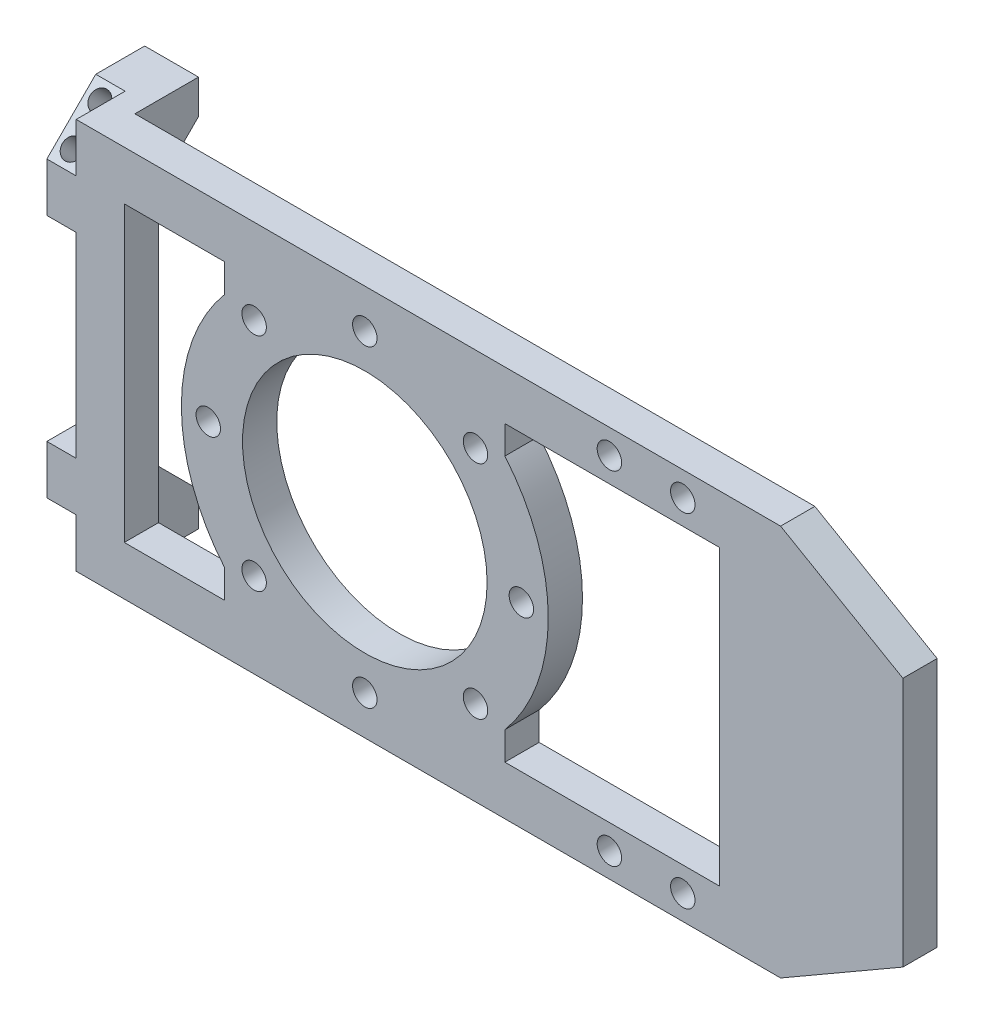
from build123d import *

# Parameters (mm, degrees)
SKETCH1_W           = 150
SKETCH1_H           = 80
BOSS_EXTRUDE1_DEPTH = 7
SKETCH2_W           = 6
SKETCH2_H           = 40
CUT_EXTRUDE2_DEPTH  = 7
SKETCH3_R           = 25
CUT_EXTRUDE3_DEPTH  = 7
CUT_EXTRUDE5_DEPTH  = 7
CUT_EXTRUDE6_DEPTH  = 7
SKETCH6_R           = 2.5
CUT_EXTRUDE7_DEPTH  = 7
BOSS_EXTRUDE2_DEPTH = 6
CUT_EXTRUDE8_DEPTH  = 6
SKETCH10_W          = 6
SKETCH10_H          = 20
BOSS_EXTRUDE3_DEPTH = 13
CUT_EXTRUDE9_DEPTH  = 13
SKETCH12_R          = 2.5
CUT_EXTRUDE10_DEPTH = 13
BOSS_EXTRUDE5_DEPTH = 5
SKETCH14_R          = 2
CUT_EXTRUDE11_DEPTH = 20.091883092
CUT_EXTRUDE13_DEPTH = 6
BOSS_EXTRUDE6_DEPTH = 7


with BuildPart() as part:
    # Sketch1 → Boss-Extrude1 (new body)
    with BuildSketch(Plane.XY):
        with Locations((75, 40)):
            Rectangle(SKETCH1_W, SKETCH1_H)
    extrude(amount=BOSS_EXTRUDE1_DEPTH)

    # Sketch2 → Cut-Extrude2 (cut)
    with BuildSketch(Plane.XY.offset(7)):
        with Locations((3, 40)):
            Rectangle(SKETCH2_W, SKETCH2_H)
    extrude(amount=-CUT_EXTRUDE2_DEPTH, mode=Mode.SUBTRACT)

    # Sketch3 → Cut-Extrude3 (cut)
    with BuildSketch(Plane.XY.offset(7)):
        with Locations((65, 40)):
            Circle(SKETCH3_R)
    extrude(amount=-CUT_EXTRUDE3_DEPTH, mode=Mode.SUBTRACT)

    # Sketch4 → Cut-Extrude5 (cut)
    with BuildSketch(Plane.XY.offset(7)):
        with BuildLine():
            Line((15.828446624, 69.975175599), (15.828446624, 10.024824401))
            Line((15.828446624, 10.024824401), (36.358795003, 10.024824401))
            Line((36.358795003, 10.024824401), (36.358795003, 15.793980576))
            ThreePointArc((36.358795003, 15.793980576), (27.5, 40), (36.358795003, 64.206019424))
            Line((36.358795003, 64.206019424), (36.358795003, 69.975175599))
            Line((36.358795003, 69.975175599), (15.828446624, 69.975175599))
        make_face()
    extrude(amount=-CUT_EXTRUDE5_DEPTH, mode=Mode.SUBTRACT)

    # Sketch5 → Cut-Extrude6 (cut)
    with BuildSketch(Plane.XY.offset(7)):
        with BuildLine():
            Line((93.631196157, 69.975175599), (93.631196157, 64.217857185))
            ThreePointArc((93.631196157, 64.217857185), (102.5, 40), (93.631196157, 15.782142815))
            Line((93.631196157, 15.782142815), (93.631196157, 10.024824401))
            Line((93.631196157, 10.024824401), (137.533061217, 10.024824401))
            Line((137.533061217, 10.024824401), (137.533061217, 69.975175599))
            Line((137.533061217, 69.975175599), (93.631196157, 69.975175599))
        make_face()
    extrude(amount=-CUT_EXTRUDE6_DEPTH, mode=Mode.SUBTRACT)

    # Sketch6 → Cut-Extrude7 (cut)
    with BuildSketch(Plane.XY.offset(7)):
        with Locations((97, 40)):
            Circle(SKETCH6_R)
        with Locations((87.627416998, 17.372583002)):
            Circle(SKETCH6_R)
        with Locations((65, 8)):
            Circle(SKETCH6_R)
        with Locations((42.372583002, 17.372583002)):
            Circle(SKETCH6_R)
        with Locations((33, 40)):
            Circle(SKETCH6_R)
        with Locations((42.372583002, 62.627416998)):
            Circle(SKETCH6_R)
        with Locations((65, 72)):
            Circle(SKETCH6_R)
        with Locations((87.627416998, 62.627416998)):
            Circle(SKETCH6_R)
    extrude(amount=-CUT_EXTRUDE7_DEPTH, mode=Mode.SUBTRACT)

    # Sketch8 → Boss-Extrude2 (add)
    with BuildSketch(Plane.ZY):
        Polygon((0, 60), (-20, 80), (0, 80), align=None)
    extrude(amount=-BOSS_EXTRUDE2_DEPTH)

    # Sketch9 → Cut-Extrude8 (cut)
    with BuildSketch(Plane.ZY):
        Polygon((-13, 80), (-13, 73), (-20, 80), align=None)
    extrude(amount=-CUT_EXTRUDE8_DEPTH, mode=Mode.SUBTRACT)

    # Sketch10 → Boss-Extrude3 (add)
    with BuildSketch(Plane(origin=(0, 0, 0), x_dir=(-1, 0, 0), z_dir=(0, 0, -1))):
        with Locations((-3, 10)):
            Rectangle(SKETCH10_W, SKETCH10_H)
    extrude(amount=BOSS_EXTRUDE3_DEPTH)

    # Sketch11 → Cut-Extrude9 (cut)
    with BuildSketch(Plane.ZY):
        Polygon((0, 20), (-13, 7), (-13, 20), align=None)
    extrude(amount=-CUT_EXTRUDE9_DEPTH, mode=Mode.SUBTRACT)

    # Sketch12 → Cut-Extrude10 (cut)
    with BuildSketch(Plane.XY.offset(7)):
        with Locations((130, 75)):
            Circle(SKETCH12_R)
        with Locations((115, 75)):
            Circle(SKETCH12_R)
        with Locations((130, 5)):
            Circle(SKETCH12_R)
        with Locations((115, 5)):
            Circle(SKETCH12_R)
    extrude(amount=-CUT_EXTRUDE10_DEPTH, mode=Mode.SUBTRACT)

    # Sketch13 → Boss-Extrude5 (add)
    with BuildSketch(Plane(origin=(6, 0, 0), x_dir=(0, 0, -1), z_dir=(1, 0, 0))):
        Polygon((0, 60), (13, 73), (13, 80), (0, 80), align=None)
        Polygon((13, 0), (0, 0), (0, 20), (13, 7), align=None)
    extrude(amount=BOSS_EXTRUDE5_DEPTH)

    # Sketch14 → Cut-Extrude11 (cut, through all)
    with BuildSketch(Plane(origin=(0, 30, 30), x_dir=(1, 0, 0), z_dir=(0, -0.707106781, -0.707106781))):
        with Locations((3, -47.618795027)):
            Circle(SKETCH14_R)
        with Locations((3, -55.618795027)):
            Circle(SKETCH14_R)
    cut_extrude11 = extrude(amount=-CUT_EXTRUDE11_DEPTH, mode=Mode.SUBTRACT)

    # Sketch15 → Cut-Extrude13 (cut)
    with BuildSketch(Plane.ZY):
        Polygon((7, 70), (-3, 80), (7, 80), align=None)
        Polygon((-3, 0), (7, 0), (7, 10), align=None)
    extrude(amount=-CUT_EXTRUDE13_DEPTH, mode=Mode.SUBTRACT)

    # Mirror1: Cut-Extrude11 across plane
    add(cut_extrude11.mirror(Plane(origin=(0, 40, 0), x_dir=(0, 0, 1), z_dir=(0, -1, 0))), mode=Mode.SUBTRACT)

    # Sketch17 → Boss-Extrude6 (add)
    with BuildSketch(Plane.XY.offset(7)):
        Polygon((150, 80), (175, 65.56624327), (175, 14.43375673), (150, 0), align=None)
    extrude(amount=-BOSS_EXTRUDE6_DEPTH)


solid = part.part
